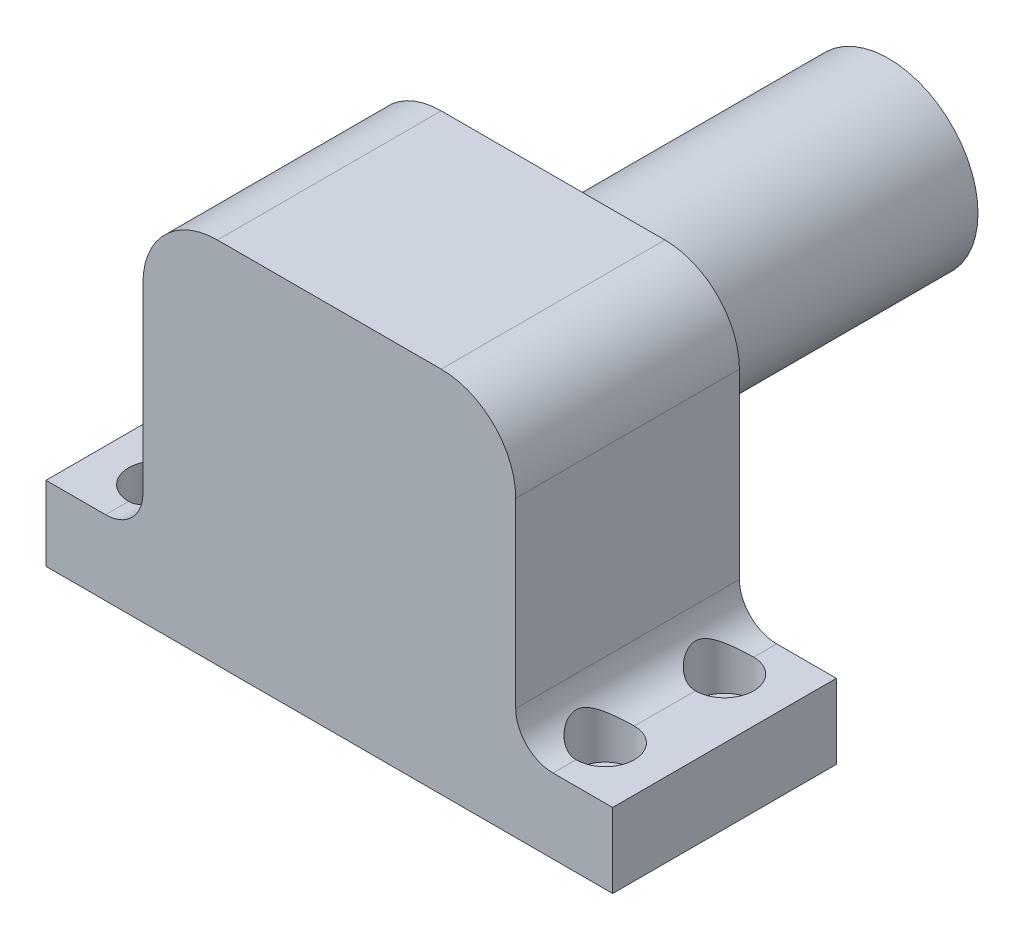
from build123d import *

# Parameters (mm, degrees)
SKETCH1_R           = 12
BOSS_EXTRUDE1_DEPTH = 45
SKETCH2_W           = 50
SKETCH2_H           = 49.413522
BOSS_EXTRUDE2_DEPTH = 30
FILLET1_R           = 5
FILLET2_R           = 10
SKETCH3_W           = 13
SKETCH3_H           = 10
BOSS_EXTRUDE3_DEPTH = 30
FILLET3_R           = 5
SKETCH4_R           = 2
CUT_EXTRUDE1_DEPTH  = 50.413522
SKETCH6_R           = 3.9116
CUT_EXTRUDE2_DEPTH  = 44.413522


with BuildPart() as part:
    # Sketch1 → Boss-Extrude1 (new body)
    with BuildSketch(Plane.XY):
        Circle(SKETCH1_R)
    extrude(amount=BOSS_EXTRUDE1_DEPTH)

    # Sketch2 → Boss-Extrude2 (add)
    with BuildSketch(Plane.XY.offset(45)):
        with Locations((0, -3.793008753)):
            Rectangle(SKETCH2_W, SKETCH2_H)
    extrude(amount=BOSS_EXTRUDE2_DEPTH)

    # Fillet1
    fillet1_edges = [part.edges().sort_by_distance(p)[0] for p in [
        (-12, 0, 45),
    ]]
    fillet(fillet1_edges, radius=FILLET1_R)

    # Fillet2
    fillet2_edges = [part.edges().sort_by_distance(p)[0] for p in [
        (-25, 20.913752247, 60),
        (25, 20.913752247, 60),
    ]]
    fillet(fillet2_edges, radius=FILLET2_R)

    # Sketch3 → Boss-Extrude3 (add)
    with BuildSketch(Plane.XY.offset(75)):
        with Locations((-31.5, -23.499769753)):
            Rectangle(SKETCH3_W, SKETCH3_H)
        with Locations((31.5, -23.499769753)):
            Rectangle(SKETCH3_W, SKETCH3_H)
    extrude(amount=-BOSS_EXTRUDE3_DEPTH)

    # Fillet3
    fillet3_edges = [part.edges().sort_by_distance(p)[0] for p in [
        (-25, -18.499769753, 60),
        (25, -18.499769753, 60),
    ]]
    fillet(fillet3_edges, radius=FILLET3_R)

    # Sketch4 → Cut-Extrude1 (cut, through all)
    with BuildSketch(Plane.XZ.offset(28.499769753)):
        with Locations((-30, 68)):
            Circle(SKETCH4_R)
        with Locations((-30, 52)):
            Circle(SKETCH4_R)
        with Locations((30, 68)):
            Circle(SKETCH4_R)
        with Locations((30, 52)):
            Circle(SKETCH4_R)
    extrude(amount=-CUT_EXTRUDE1_DEPTH, mode=Mode.SUBTRACT)

    # Sketch6 → Cut-Extrude2 (cut)
    with BuildSketch(Plane(origin=(0, 20.913752247, 0), x_dir=(1, 0, 0), z_dir=(0, 1, 0))):
        with Locations((-30, -52)):
            Circle(SKETCH6_R)
        with Locations((-30, -68)):
            Circle(SKETCH6_R)
        with Locations((30, -52)):
            Circle(SKETCH6_R)
        with Locations((30, -68)):
            Circle(SKETCH6_R)
    extrude(amount=-CUT_EXTRUDE2_DEPTH, mode=Mode.SUBTRACT)


solid = part.part
